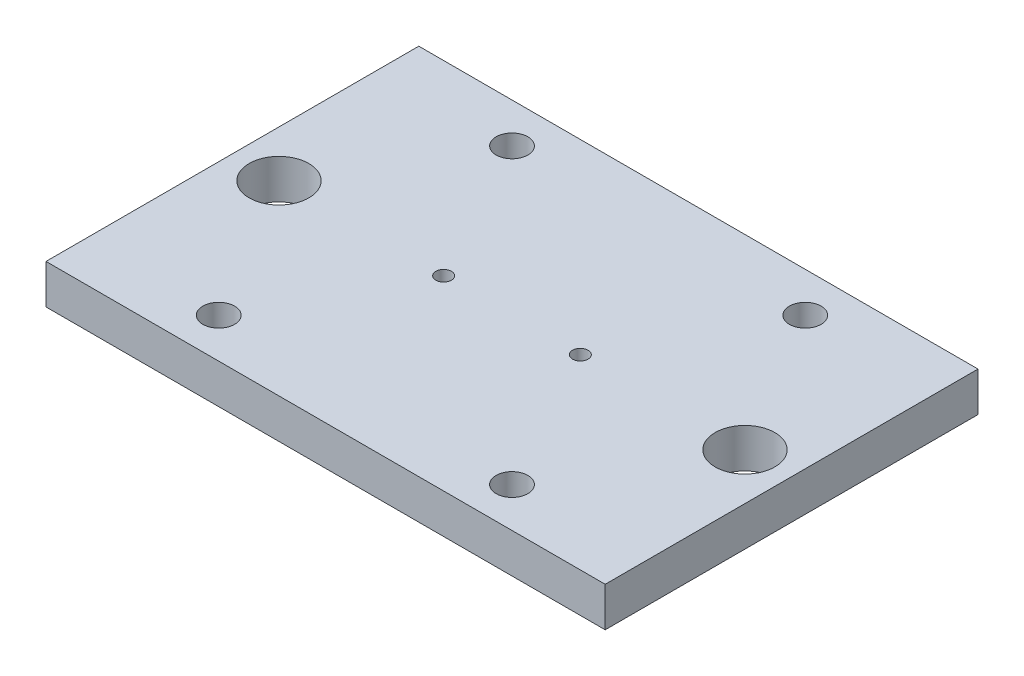
from build123d import *

# Parameters (mm, degrees)
SKETCH1_W           = 90
SKETCH1_H           = 60
SKETCH1_R           = 4.8
SKETCH1_R_2         = 2.55
BOSS_EXTRUDE1_DEPTH = 6.35
SKETCH3_R           = 1.25
CUT_EXTRUDE1_DEPTH  = 8


with BuildPart() as part:
    # Sketch1 → Boss-Extrude1 (new body)
    with BuildSketch(Plane(origin=(0, 0, 0), x_dir=(1, 0, 0), z_dir=(0, 1, 0))):
        Rectangle(SKETCH1_W, SKETCH1_H)
        with Locations((-37.5, 0)):
            Circle(SKETCH1_R, mode=Mode.SUBTRACT)
        with Locations((37.5, 0)):
            Circle(SKETCH1_R, mode=Mode.SUBTRACT)
        with Locations((-23.6, -23.6)):
            Circle(SKETCH1_R_2, mode=Mode.SUBTRACT)
        with Locations((23.6, -23.6)):
            Circle(SKETCH1_R_2, mode=Mode.SUBTRACT)
        with Locations((23.6, 23.6)):
            Circle(SKETCH1_R_2, mode=Mode.SUBTRACT)
        with Locations((-23.6, 23.6)):
            Circle(SKETCH1_R_2, mode=Mode.SUBTRACT)
    extrude(amount=BOSS_EXTRUDE1_DEPTH)

    # Sketch3 → Cut-Extrude1 (cut)
    with BuildSketch(Plane(origin=(0, 6.35, 0), x_dir=(1, 0, 0), z_dir=(0, 1, 0))):
        with Locations((-11, 0)):
            Circle(SKETCH3_R)
        with Locations((11, 0)):
            Circle(SKETCH3_R)
    extrude(amount=-CUT_EXTRUDE1_DEPTH, mode=Mode.SUBTRACT)


solid = part.part
